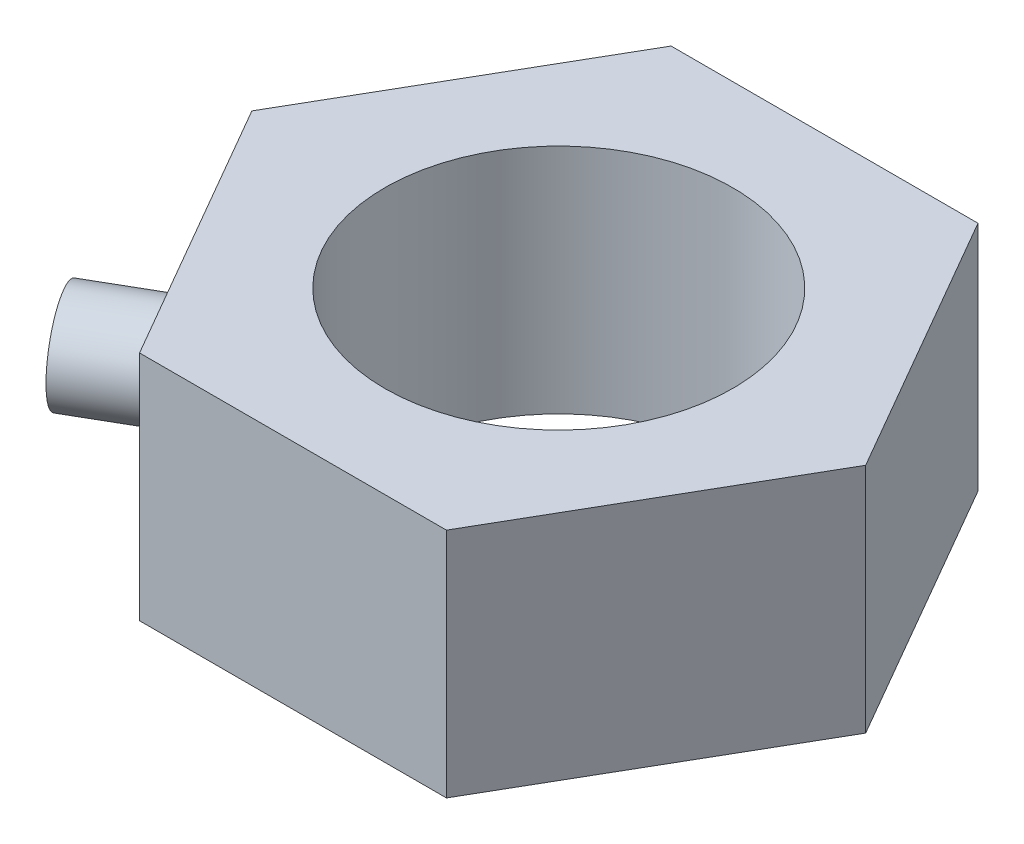
from build123d import *

# Parameters (mm, degrees)
ESTRUSIONE_ESTRUSIONE3_DEPTH = 1.2
SCHIZZO3_R                   = 1.8
TAGLIO_ESTRUSIONE1_DEPTH     = 50
SCHIZZO4_R                   = 0.5
ESTRUSIONE_ESTRUSIONE4_DEPTH = 1


with BuildPart() as part:
    # Schizzo2 → Estrusione-Estrusione3 (new body, symmetric)
    with BuildSketch(Plane(origin=(0, 0, 0), x_dir=(1, 0, 0), z_dir=(0, 1, 0))):
        Polygon((3.175426481, 0), (1.58771324, 2.75), (-1.58771324, 2.75), (-3.175426481, 0), (-1.58771324, -2.75), (1.58771324, -2.75), align=None)
    extrude(amount=ESTRUSIONE_ESTRUSIONE3_DEPTH, both=True)

    # Schizzo3 → Taglio-Estrusione1 (cut, symmetric)
    with BuildSketch(Plane(origin=(0, 1.2, 0), x_dir=(1, 0, 0), z_dir=(0, 1, 0))):
        Circle(SCHIZZO3_R)
    extrude(amount=TAGLIO_ESTRUSIONE1_DEPTH, both=True, mode=Mode.SUBTRACT)

    # Schizzo4 → Estrusione-Estrusione4 (add)
    with BuildSketch(Plane(origin=(-2.38156986, 0, 1.375), x_dir=(0.5, 0, 0.866025404), z_dir=(-0.866025404, 0, 0.5))):
        Circle(SCHIZZO4_R)
    extrude(amount=ESTRUSIONE_ESTRUSIONE4_DEPTH)


solid = part.part
